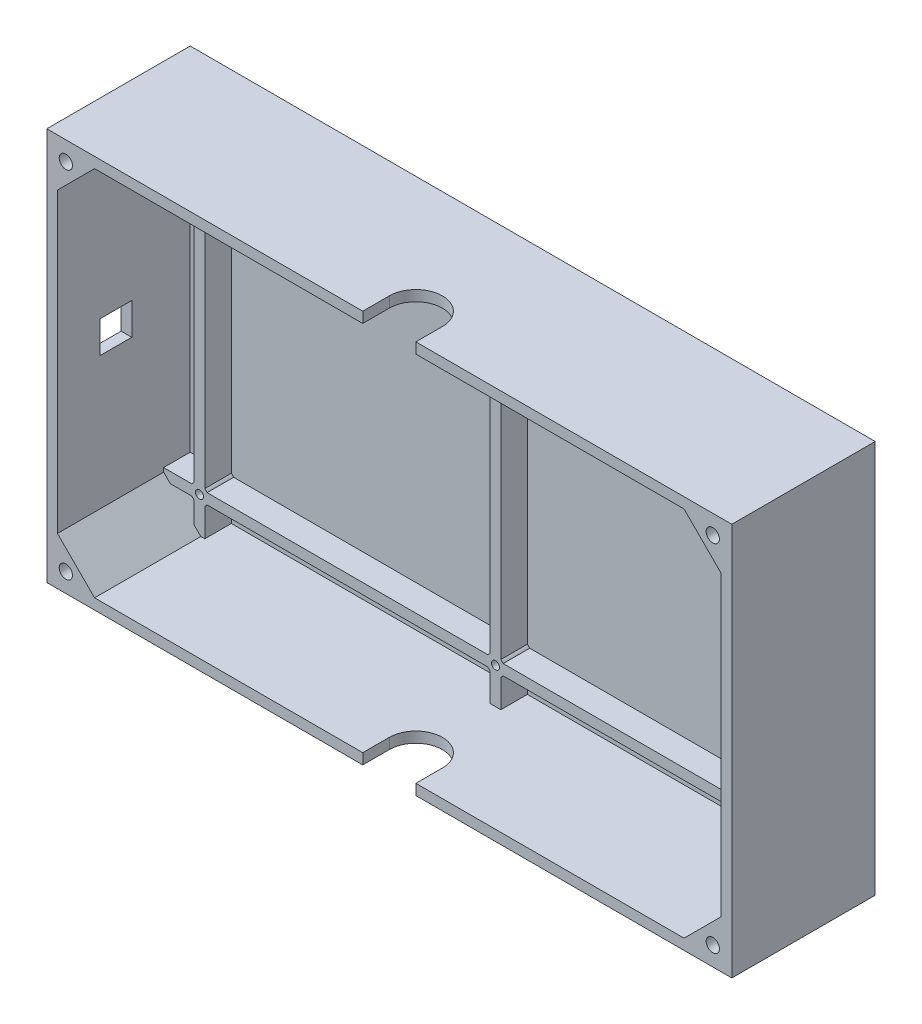
from build123d import *

# Parameters (mm, degrees)
ESQUISSE1_W             = 258
ESQUISSE1_H             = 148
ESQUISSE1_R             = 2.5
ESQUISSE1_R_2           = 1.5
BOSS_EXTRU_2_DEPTH      = 10
ESQUISSE1_5_W           = 258
ESQUISSE1_5_H           = 148
BOSS_EXTRU_3_DEPTH      = 4
ESQUISSE2_W             = 258
ESQUISSE2_H             = 148
ESQUISSE2_R             = 2.5
BOSS_EXTRU_5_DEPTH      = 40
ENL_V_MAT_EXTRU_1_REACH = 271.243
ESQUISSE4_W             = 12
ESQUISSE4_H             = 12
ENL_V_MAT_EXTRU_2_REACH = 201.692
ENL_V_MAT_EXTRU_3_REACH = 201.692


with BuildPart() as part:
    # Esquisse1 → Boss.-Extru.2 (new body)
    with BuildSketch(Plane.XY):
        Rectangle(ESQUISSE1_W, ESQUISSE1_H)
        with BuildLine():
            Line((-109.5, 59.372281323), (-109.5, 70))
            Line((-109.5, 70), (-2, 70))
            Line((-2, 70), (-2, 59.372281323))
            ThreePointArc((-2, 59.372281323), (-2.474873734, 58.974873734), (-2.872281323, 58.5))
            Line((-2.872281323, 58.5), (-108.627718677, 58.5))
            ThreePointArc((-108.627718677, 58.5), (-109.025126266, 58.974873734), (-109.5, 59.372281323))
        make_face(mode=Mode.SUBTRACT)
        with BuildLine():
            Line((-113.5, 67.5), (-113.5, 59.372281323))
            ThreePointArc((-113.5, 59.372281323), (-113.974873734, 58.974873734), (-114.372281323, 58.5))
            Line((-114.372281323, 58.5), (-122.5, 58.5))
            Line((-122.5, 58.5), (-113.5, 67.5))
        make_face(mode=Mode.SUBTRACT)
        with Locations((-121.8320772, -66.8320772)):
            Circle(ESQUISSE1_R, mode=Mode.SUBTRACT)
        with Locations((121.8320772, -66.8320772)):
            Circle(ESQUISSE1_R, mode=Mode.SUBTRACT)
        with Locations((-121.8320772, 66.8320772)):
            Circle(ESQUISSE1_R, mode=Mode.SUBTRACT)
        with Locations((121.8320772, 66.8320772)):
            Circle(ESQUISSE1_R, mode=Mode.SUBTRACT)
        with BuildLine():
            Line((-125, -54.5), (-125, 54.5))
            Line((-125, 54.5), (-114.372281323, 54.5))
            ThreePointArc((-114.372281323, 54.5), (-113.974873734, 54.025126266), (-113.5, 53.627718677))
            Line((-113.5, 53.627718677), (-113.5, -53.627718677))
            ThreePointArc((-113.5, -53.627718677), (-113.974873734, -54.025126266), (-114.372281323, -54.5))
            Line((-114.372281323, -54.5), (-125, -54.5))
        make_face(mode=Mode.SUBTRACT)
        with BuildLine():
            Line((-113.5, -67.5), (-122.5, -58.5))
            Line((-122.5, -58.5), (-114.372281323, -58.5))
            ThreePointArc((-114.372281323, -58.5), (-113.974873734, -58.974873734), (-113.5, -59.372281323))
            Line((-113.5, -59.372281323), (-113.5, -67.5))
        make_face(mode=Mode.SUBTRACT)
        with BuildLine():
            Line((-2, -70), (-109.5, -70))
            Line((-109.5, -70), (-109.5, -59.372281323))
            ThreePointArc((-109.5, -59.372281323), (-109.025126266, -58.974873734), (-108.627718677, -58.5))
            Line((-108.627718677, -58.5), (-2.872281323, -58.5))
            ThreePointArc((-2.872281323, -58.5), (-2.474873734, -58.974873734), (-2, -59.372281323))
            Line((-2, -59.372281323), (-2, -70))
        make_face(mode=Mode.SUBTRACT)
        with BuildLine():
            Line((109.5, -70), (2, -70))
            Line((2, -70), (2, -59.372281323))
            ThreePointArc((2, -59.372281323), (2.474873734, -58.974873734), (2.872281323, -58.5))
            Line((2.872281323, -58.5), (108.627718677, -58.5))
            ThreePointArc((108.627718677, -58.5), (109.025126266, -58.974873734), (109.5, -59.372281323))
            Line((109.5, -59.372281323), (109.5, -70))
        make_face(mode=Mode.SUBTRACT)
        with BuildLine():
            Line((122.5, -58.5), (113.5, -67.5))
            Line((113.5, -67.5), (113.5, -59.372281323))
            ThreePointArc((113.5, -59.372281323), (113.974873734, -58.974873734), (114.372281323, -58.5))
            Line((114.372281323, -58.5), (122.5, -58.5))
        make_face(mode=Mode.SUBTRACT)
        with BuildLine():
            Line((125, 54.5), (125, -54.5))
            Line((125, -54.5), (114.372281323, -54.5))
            ThreePointArc((114.372281323, -54.5), (113.974873734, -54.025126266), (113.5, -53.627718677))
            Line((113.5, -53.627718677), (113.5, 53.627718677))
            ThreePointArc((113.5, 53.627718677), (113.974873734, 54.025126266), (114.372281323, 54.5))
            Line((114.372281323, 54.5), (125, 54.5))
        make_face(mode=Mode.SUBTRACT)
        with BuildLine():
            Line((113.5, 67.5), (122.5, 58.5))
            Line((122.5, 58.5), (114.372281323, 58.5))
            ThreePointArc((114.372281323, 58.5), (113.974873734, 58.974873734), (113.5, 59.372281323))
            Line((113.5, 59.372281323), (113.5, 67.5))
        make_face(mode=Mode.SUBTRACT)
        with BuildLine():
            Line((2, 70), (109.5, 70))
            Line((109.5, 70), (109.5, 59.372281323))
            ThreePointArc((109.5, 59.372281323), (109.025126266, 58.974873734), (108.627718677, 58.5))
            Line((108.627718677, 58.5), (2.872281323, 58.5))
            ThreePointArc((2.872281323, 58.5), (2.474873734, 58.974873734), (2, 59.372281323))
            Line((2, 59.372281323), (2, 70))
        make_face(mode=Mode.SUBTRACT)
        with BuildLine():
            ThreePointArc((-109.5, 53.627718677), (-109.025126266, 54.025126266), (-108.627718677, 54.5))
            Line((-108.627718677, 54.5), (-2.872281323, 54.5))
            ThreePointArc((-2.872281323, 54.5), (-2.474873734, 54.025126266), (-2, 53.627718677))
            Line((-2, 53.627718677), (-2, -53.627718677))
            ThreePointArc((-2, -53.627718677), (-2.474873734, -54.025126266), (-2.872281323, -54.5))
            Line((-2.872281323, -54.5), (-108.627718677, -54.5))
            ThreePointArc((-108.627718677, -54.5), (-109.025126266, -54.025126266), (-109.5, -53.627718677))
            Line((-109.5, -53.627718677), (-109.5, 53.627718677))
        make_face(mode=Mode.SUBTRACT)
        with Locations((-111.5, 56.5)):
            Circle(ESQUISSE1_R_2, mode=Mode.SUBTRACT)
        with Locations((-111.5, -56.5)):
            Circle(ESQUISSE1_R_2, mode=Mode.SUBTRACT)
        with BuildLine():
            ThreePointArc((2.872281323, -54.5), (2.474873734, -54.025126266), (2, -53.627718677))
            Line((2, -53.627718677), (2, 53.627718677))
            ThreePointArc((2, 53.627718677), (2.474873734, 54.025126266), (2.872281323, 54.5))
            Line((2.872281323, 54.5), (108.627718677, 54.5))
            ThreePointArc((108.627718677, 54.5), (109.025126266, 54.025126266), (109.5, 53.627718677))
            Line((109.5, 53.627718677), (109.5, -53.627718677))
            ThreePointArc((109.5, -53.627718677), (109.025126266, -54.025126266), (108.627718677, -54.5))
            Line((108.627718677, -54.5), (2.872281323, -54.5))
        make_face(mode=Mode.SUBTRACT)
        with Locations((0, -56.5)):
            Circle(ESQUISSE1_R_2, mode=Mode.SUBTRACT)
        with Locations((111.5, -56.5)):
            Circle(ESQUISSE1_R_2, mode=Mode.SUBTRACT)
        with Locations((111.5, 56.5)):
            Circle(ESQUISSE1_R_2, mode=Mode.SUBTRACT)
        with Locations((0, 56.5)):
            Circle(ESQUISSE1_R_2, mode=Mode.SUBTRACT)
    extrude(amount=BOSS_EXTRU_2_DEPTH)

    # Esquisse1_5 → Boss.-Extru.3 (add)
    with BuildSketch(Plane.XY):
        Rectangle(ESQUISSE1_5_W, ESQUISSE1_5_H)
    extrude(amount=-BOSS_EXTRU_3_DEPTH)

    # Esquisse2 → Boss.-Extru.5 (add)
    with BuildSketch(Plane.XY.offset(10)):
        Rectangle(ESQUISSE2_W, ESQUISSE2_H)
        with Locations((-121.8320772, 66.8320772)):
            Circle(ESQUISSE2_R, mode=Mode.SUBTRACT)
        with Locations((-121.8320772, -66.8320772)):
            Circle(ESQUISSE2_R, mode=Mode.SUBTRACT)
        with Locations((121.8320772, -66.8320772)):
            Circle(ESQUISSE2_R, mode=Mode.SUBTRACT)
        with Locations((121.8320772, 66.8320772)):
            Circle(ESQUISSE2_R, mode=Mode.SUBTRACT)
        Polygon((-111, 70), (111, 70), (125, 56), (125, -56), (111, -70), (-111, -70), (-125, -56), (-125, 56), align=None, mode=Mode.SUBTRACT)
    extrude(amount=BOSS_EXTRU_5_DEPTH)

    # Esquisse4 → Enlèv. mat.-Extru.1 (cut, up to next)
    with BuildSketch(Plane(origin=(-125, 0, 0), x_dir=(0, 0, -1), z_dir=(1, 0, 0)), mode=Mode.PRIVATE) as enl_v_mat_extru_1_sk1:
        with Locations((-28, 0)):
            Rectangle(ESQUISSE4_W, ESQUISSE4_H)
    enl_v_mat_extru_1_tool1 = extrude(enl_v_mat_extru_1_sk1.sketch, amount=-ENL_V_MAT_EXTRU_1_REACH, mode=Mode.PRIVATE) & part.part
    add(enl_v_mat_extru_1_tool1.solids().sort_by_distance((-125, 0, 28))[0], mode=Mode.SUBTRACT)

    # Esquisse6 → Enlèv. mat.-Extru.2 (cut, up to next)
    with BuildSketch(Plane(origin=(0, -70, 0), x_dir=(1, 0, 0), z_dir=(0, 1, 0)), mode=Mode.PRIVATE) as enl_v_mat_extru_2_sk1:
        with BuildLine():
            Line((10, -40), (10, -50))
            Line((10, -50), (-10, -50))
            Line((-10, -50), (-10, -40))
            ThreePointArc((-10, -40), (0, -30), (10, -40))
        make_face()
    enl_v_mat_extru_2_tool1 = extrude(enl_v_mat_extru_2_sk1.sketch, amount=-ENL_V_MAT_EXTRU_2_REACH, mode=Mode.PRIVATE) & part.part
    add(enl_v_mat_extru_2_tool1.solids().sort_by_distance((0, -70, 40.933499))[0], mode=Mode.SUBTRACT)

    # Esquisse9 → Enlèv. mat.-Extru.3 (cut, up to next)
    with BuildSketch(Plane.XZ.offset(-70), mode=Mode.PRIVATE) as enl_v_mat_extru_3_sk1:
        with BuildLine():
            Line((-10, 40), (-10, 50))
            Line((-10, 50), (10, 50))
            Line((10, 50), (10, 40))
            ThreePointArc((10, 40), (0, 30), (-10, 40))
        make_face()
    enl_v_mat_extru_3_tool1 = extrude(enl_v_mat_extru_3_sk1.sketch, amount=-ENL_V_MAT_EXTRU_3_REACH, mode=Mode.PRIVATE) & part.part
    add(enl_v_mat_extru_3_tool1.solids().sort_by_distance((0, 70, 40.933499))[0], mode=Mode.SUBTRACT)


solid = part.part
